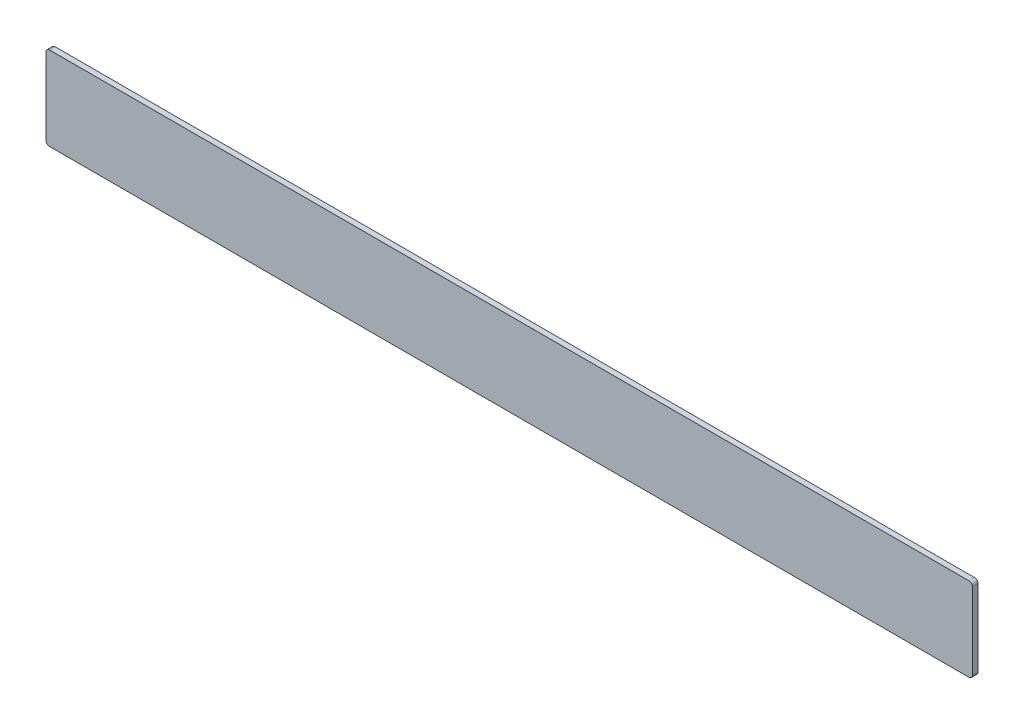
from build123d import *

# Parameters (mm, degrees)
SKETCH1_W           = 1330
SKETCH1_H           = 120
BOSS_EXTRUDE1_DEPTH = 4
FILLET1_R           = 5


with BuildPart() as part:
    # Sketch1 → Boss-Extrude1 (new body, symmetric)
    with BuildSketch(Plane.XY):
        Rectangle(SKETCH1_W, SKETCH1_H)
    extrude(amount=BOSS_EXTRUDE1_DEPTH, both=True)

    # Fillet1
    fillet1_edges = [part.edges().sort_by_distance(p)[0] for p in [
        (665, -60, 0),
        (-665, -60, 0),
        (-665, 60, 0),
        (665, 60, 0),
    ]]
    fillet(fillet1_edges, radius=FILLET1_R)


solid = part.part
